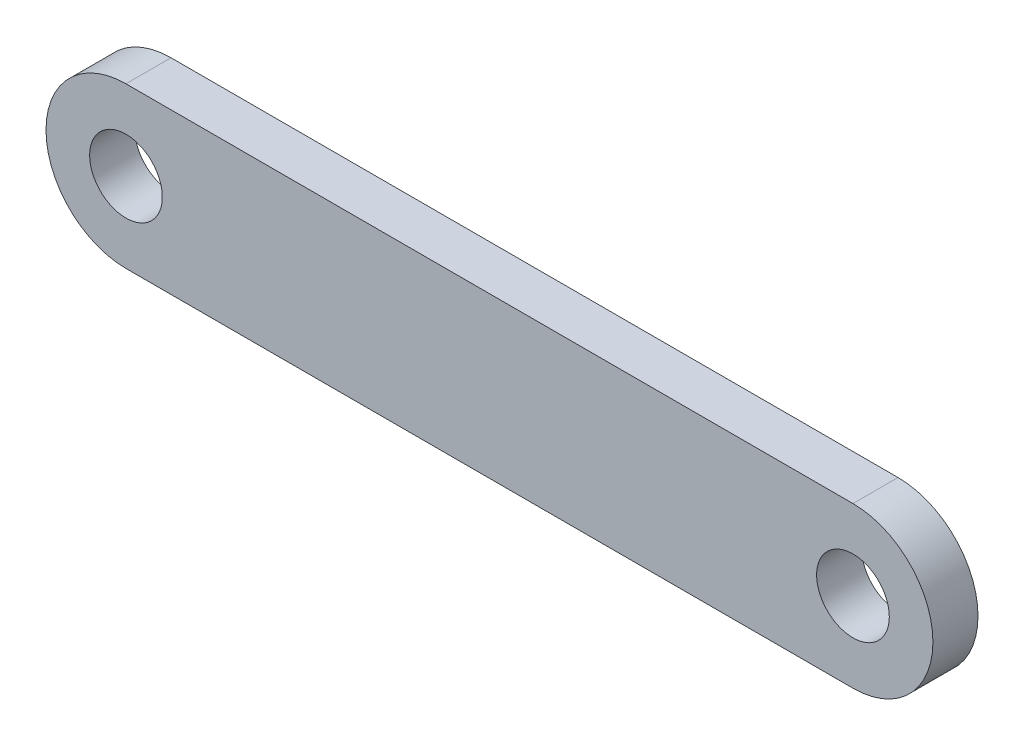
from build123d import *

# Parameters (mm, degrees)
SKETCH1_R           = 2.5
BOSS_EXTRUDE1_DEPTH = 3.1


with BuildPart() as part:
    # Sketch1 → Boss-Extrude1 (new body)
    with BuildSketch(Plane.XY):
        with BuildLine():
            Line((-25, 5.027173913), (25, 5.027173913))
            ThreePointArc((25, 5.027173913), (30.5, -0.472826087), (25, -5.972826087))
            Line((25, -5.972826087), (-25, -5.972826087))
            ThreePointArc((-25, -5.972826087), (-30.5, -0.472826087), (-25, 5.027173913))
        make_face()
        with Locations((25, -0.472826087)):
            Circle(SKETCH1_R, mode=Mode.SUBTRACT)
        with Locations((-25, -0.472826087)):
            Circle(SKETCH1_R, mode=Mode.SUBTRACT)
    extrude(amount=BOSS_EXTRUDE1_DEPTH)


solid = part.part
